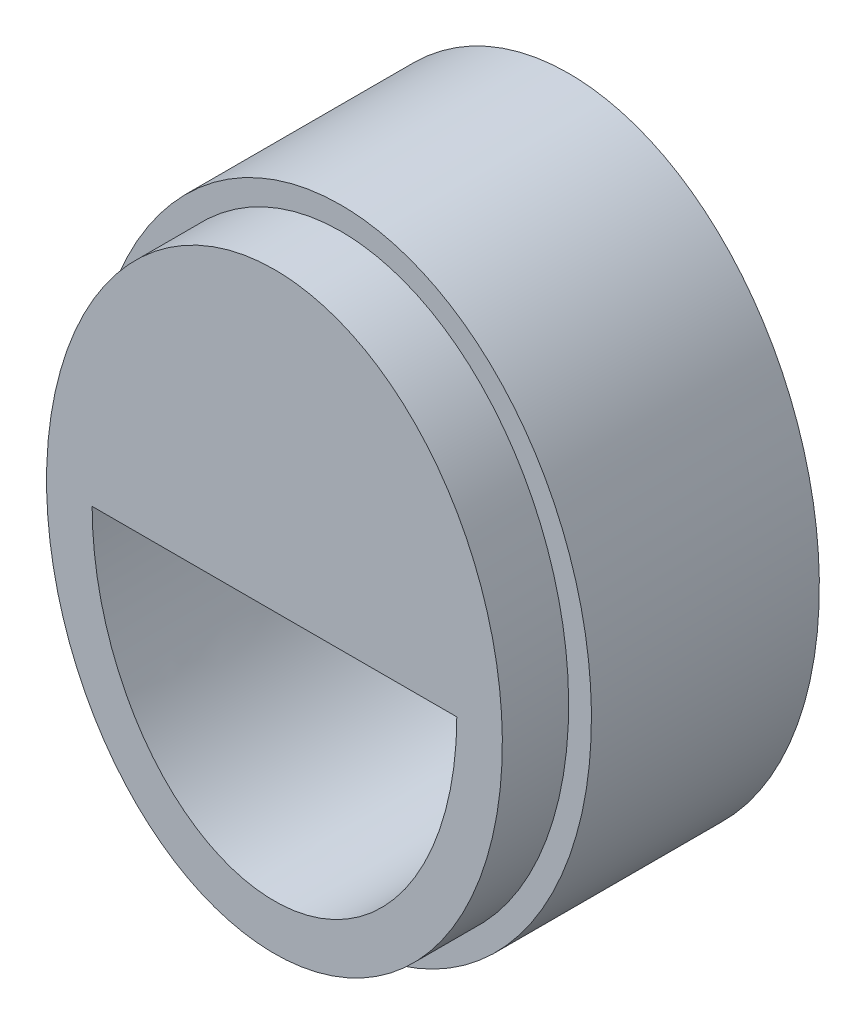
from build123d import *

# Parameters (mm, degrees)
CROQUIS1_RX                  = 14
CROQUIS1_RY                  = 11
CROQUIS1_RX_2                = 12
CROQUIS1_RY_2                = 9
SALIENTE_EXTRUIR1_DEPTH      = 10
CROQUIS2_RX                  = 13
CROQUIS2_RY                  = 10
CROQUIS2_RX_2                = 11
CROQUIS2_RY_2                = 8
SALIENTE_EXTRUIR3_DEPTH      = 2.90966046
SALIENTE_EXTRUIR3_DEPTH_BACK = 8
SALIENTE_EXTRUIR4_DEPTH      = 2


with BuildPart() as part:
    # Croquis1 → Saliente-Extruir1 (new body)
    with BuildSketch(Plane.XY):
        with Locations(Location((0, 0), (0, 0, 90))):
            Ellipse(CROQUIS1_RX, CROQUIS1_RY)
        with Locations(Location((0, 0), (0, 0, 90))):
            Ellipse(CROQUIS1_RX_2, CROQUIS1_RY_2, mode=Mode.SUBTRACT)
    extrude(amount=SALIENTE_EXTRUIR1_DEPTH)

    # Croquis2 → Saliente-Extruir3 (add, two sides)
    with BuildSketch(Plane.XY.offset(10)) as saliente_extruir3_sk:
        with Locations(Location((0, 0), (0, 0, 90))):
            Ellipse(CROQUIS2_RX, CROQUIS2_RY)
        with Locations(Location((0, 0), (0, 0, 90))):
            Ellipse(CROQUIS2_RX_2, CROQUIS2_RY_2, mode=Mode.SUBTRACT)
    extrude(amount=SALIENTE_EXTRUIR3_DEPTH)
    extrude(saliente_extruir3_sk.sketch, amount=-SALIENTE_EXTRUIR3_DEPTH_BACK)

    # Croquis4 → Saliente-Extruir4 (add)
    with BuildSketch(Plane.XY.offset(12.90966046)):
        with BuildLine():
            Line((-8, 0), (8, 0))
            add(Edge.make_bspline(
                [(8, 0), (8, 11), (0, 11), (-8, 11), (-8, 0)],
                knots=[4.71238898, 4.71238898, 4.71238898, 6.283185307, 6.283185307, 7.853981634, 7.853981634, 7.853981634], degree=2, weights=[1, 0.707106781, 1, 0.707106781, 1]))
        make_face()
    extrude(amount=-SALIENTE_EXTRUIR4_DEPTH)


solid = part.part
